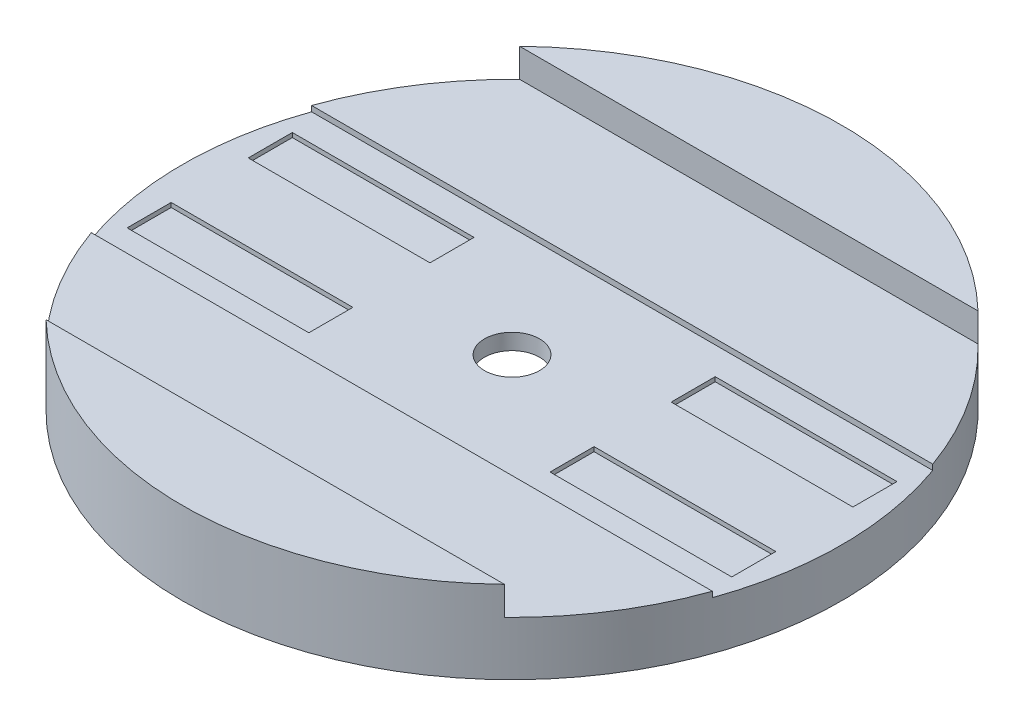
from build123d import *

# Parameters (mm, degrees)
SKETCH1_R           = 76
BOSS_EXTRUDE1_DEPTH = 19.05
CUT_EXTRUDE4_DEPTH  = 6.604
SKETCH5_R           = 6.35
CUT_EXTRUDE5_DEPTH  = 20
SKETCH13_R          = 70
CUT_EXTRUDE9_DEPTH  = 7.5
CUT_EXTRUDE11_DEPTH = 1.27
SKETCH16_W          = 41.91
SKETCH16_H          = 10.16
CUT_EXTRUDE12_DEPTH = 1.016


with BuildPart() as part:
    # Sketch1 → Boss-Extrude1 (new body)
    with BuildSketch(Plane(origin=(0, 0, 0), x_dir=(1, 0, 0), z_dir=(0, 1, 0))):
        Circle(SKETCH1_R)
    extrude(amount=BOSS_EXTRUDE1_DEPTH)

    # Sketch2 → Cut-Extrude4 (cut)
    with BuildSketch(Plane(origin=(0, 19.05, 0), x_dir=(1, 0, 0), z_dir=(0, 1, 0))):
        with BuildLine():
            Line((-58.007955522, 54.61), (58.007955522, 54.61))
            ThreePointArc((58.007955522, 54.61), (112.617955522, 0), (58.007955522, -54.61))
            Line((58.007955522, -54.61), (-58.007955522, -54.61))
            ThreePointArc((-58.007955522, -54.61), (-112.617955522, 0), (-58.007955522, 54.61))
        make_face()
    extrude(amount=-CUT_EXTRUDE4_DEPTH, mode=Mode.SUBTRACT)

    # Sketch5 → Cut-Extrude5 (cut)
    with BuildSketch(Plane(origin=(0, 12.446, 0), x_dir=(1, 0, 0), z_dir=(0, 1, 0))):
        Circle(SKETCH5_R)
    extrude(amount=-CUT_EXTRUDE5_DEPTH, mode=Mode.SUBTRACT)

    # Sketch13 → Cut-Extrude9 (cut)
    with BuildSketch(Plane(origin=(0, 0, 0), x_dir=(-1, 0, 0), z_dir=(0, -1, 0))):
        Circle(SKETCH13_R)
    extrude(amount=-CUT_EXTRUDE9_DEPTH, mode=Mode.SUBTRACT)

    # Sketch15 → Cut-Extrude11 (cut)
    with BuildSketch(Plane(origin=(0, 12.446, 0), x_dir=(1, 0, 0), z_dir=(0, 1, 0))):
        with BuildLine():
            Line((76, -25.4), (-76, -25.4))
            ThreePointArc((-76, -25.4), (-101.4, 0), (-76, 25.4))
            Line((-76, 25.4), (76, 25.4))
            ThreePointArc((76, 25.4), (101.4, 0), (76, -25.4))
        make_face()
    extrude(amount=-CUT_EXTRUDE11_DEPTH, mode=Mode.SUBTRACT)

    # Sketch16 → Cut-Extrude12 (cut)
    with BuildSketch(Plane(origin=(0, 11.176, 0), x_dir=(1, 0, 0), z_dir=(0, 1, 0))):
        with Locations((-48.768, -13.97)):
            Rectangle(SKETCH16_W, SKETCH16_H)
        with Locations((-48.768, 13.97)):
            Rectangle(SKETCH16_W, SKETCH16_H)
        with Locations((48.768, -13.97)):
            Rectangle(SKETCH16_W, SKETCH16_H)
        with Locations((48.768, 13.97)):
            Rectangle(SKETCH16_W, SKETCH16_H)
    extrude(amount=-CUT_EXTRUDE12_DEPTH, mode=Mode.SUBTRACT)


solid = part.part
